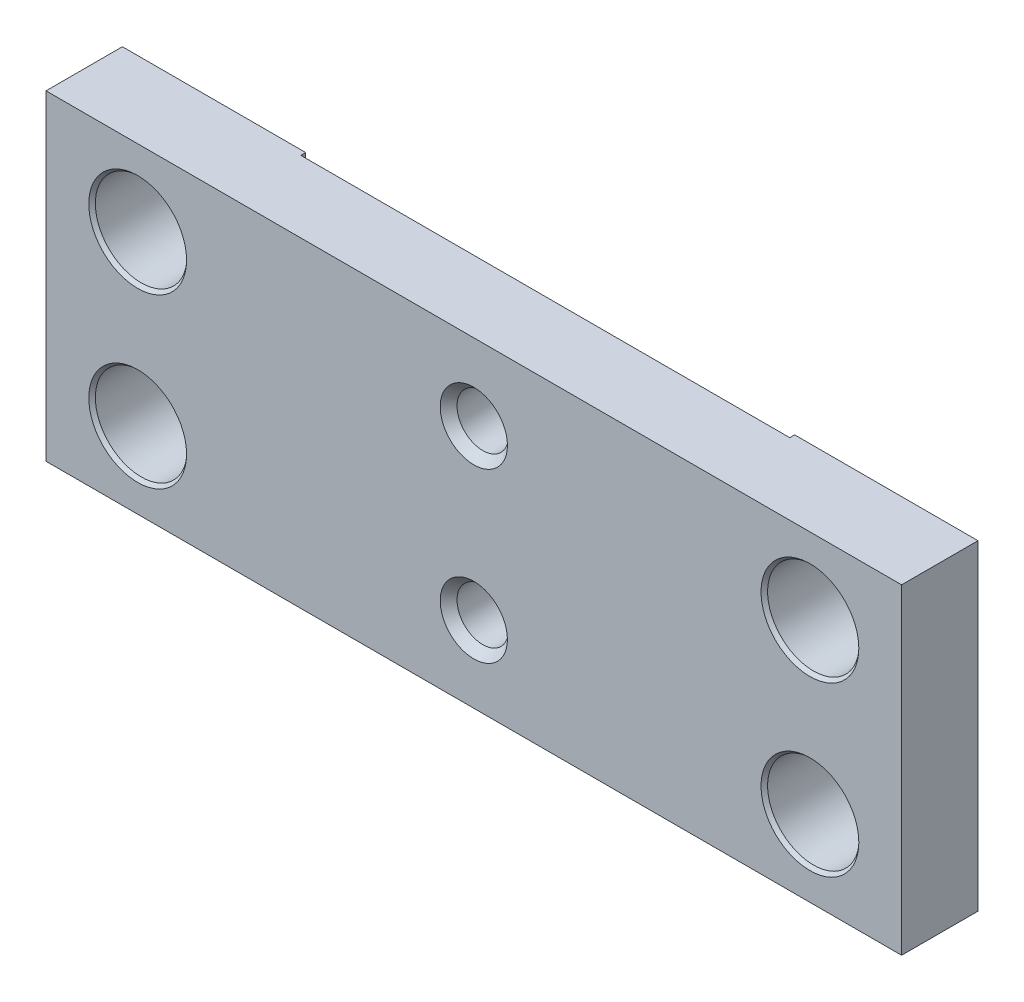
from build123d import *

# Parameters (mm, degrees)
SKETCH1_W                         = 177.8
SKETCH1_H                         = 66.675
EXTRUDE1_DEPTH                    = 15.875
F_1_2_CLEARANCE_HOLE1_AT_2_COUNT  = 2
F_1_2_CLEARANCE_HOLE1_AT_2_PITCH  = 34.925
F_1_2_CLEARANCE_HOLE1_AT_3_COUNT  = 2
F_1_2_CLEARANCE_HOLE1_AT_3_PITCH  = 139.7
F_1_2_CLEARANCE_HOLE1_AT_4_COUNT  = 2
F_1_2_CLEARANCE_HOLE1_AT_4_PITCH  = 143.999463975
SKETCH15_W                        = 101.6
SKETCH15_H                        = 66.675
CUT_EXTRUDE1_DEPTH                = 1.016
CUT_EXTRUDE2_DEPTH                = 19.05
F_1_2_13_TAPPED_HOLE1_D           = 10.71626
F_1_2_13_TAPPED_HOLE1_DEPTH       = 14.859
F_1_2_13_TAPPED_HOLE1_CSINK_D     = 13.97
F_1_2_13_TAPPED_HOLE1_CSINK_ANGLE = 82


with BuildPart() as part:
    # Sketch1 → Extrude1 (new body)
    with BuildSketch(Plane.XY):
        with Locations((0, 33.3375)):
            Rectangle(SKETCH1_W, SKETCH1_H)
    extrude(amount=EXTRUDE1_DEPTH)

    # Sketch11 → 1/2 Clearance Hole1 (revolve, cut)
    with BuildSketch(Plane(origin=(-69.85, 50.8, 15.875), x_dir=(0, -1, 0), z_dir=(1, 0, 0))):
        Polygon((0, 0), (0, 15.875), (10.16, 15.875), (9.525, 15.144516061), (9.525, 0.730483939), (10.16, 0), align=None)
    f_1_2_clearance_hole1 = revolve(axis=Axis((-69.85, 50.8, 22.225), (0, 0, -1)), mode=Mode.SUBTRACT)

    # 1/2 Clearance Hole1 at 2: 1/2 Clearance Hole1 ×2
    with Locations(*[(0, -i * F_1_2_CLEARANCE_HOLE1_AT_2_PITCH, 0) for i in range(1, F_1_2_CLEARANCE_HOLE1_AT_2_COUNT)]):
        add(f_1_2_clearance_hole1, mode=Mode.SUBTRACT)

    # 1/2 Clearance Hole1 at 3: 1/2 Clearance Hole1 ×2
    with Locations(*[(i * F_1_2_CLEARANCE_HOLE1_AT_3_PITCH, 0, 0) for i in range(1, F_1_2_CLEARANCE_HOLE1_AT_3_COUNT)]):
        add(f_1_2_clearance_hole1, mode=Mode.SUBTRACT)

    # 1/2 Clearance Hole1 at 4: 1/2 Clearance Hole1 ×2
    with Locations(*[Vector(0.9701425, -0.242535625, 0) * (i * F_1_2_CLEARANCE_HOLE1_AT_4_PITCH) for i in range(1, F_1_2_CLEARANCE_HOLE1_AT_4_COUNT)]):
        add(f_1_2_clearance_hole1, mode=Mode.SUBTRACT)

    # Sketch15 → Cut-Extrude1 (cut)
    with BuildSketch(Plane(origin=(0, 0, 0), x_dir=(-1, 0, 0), z_dir=(0, 0, -1))):
        with Locations((0, 33.3375)):
            Rectangle(SKETCH15_W, SKETCH15_H)
    extrude(amount=-CUT_EXTRUDE1_DEPTH, mode=Mode.SUBTRACT)

    # Sketch17 → Cut-Extrude2 (cut, symmetric)
    with BuildSketch(Plane(origin=(0, 0, 0), x_dir=(0, 0, -1), z_dir=(1, 0, 0))):
        Polygon((-6.35, 0), (0, 10.998522628), (0, 0), align=None)
    extrude(amount=CUT_EXTRUDE2_DEPTH, both=True, mode=Mode.SUBTRACT)

    # 1/2-13 Tapped Hole1
    with Locations(Plane.XY.offset(15.875)):
        with Locations((0, 50.8), (0, 15.875)):
            CounterSinkHole(F_1_2_13_TAPPED_HOLE1_D / 2, F_1_2_13_TAPPED_HOLE1_CSINK_D / 2, depth=F_1_2_13_TAPPED_HOLE1_DEPTH, counter_sink_angle=F_1_2_13_TAPPED_HOLE1_CSINK_ANGLE)


solid = part.part
